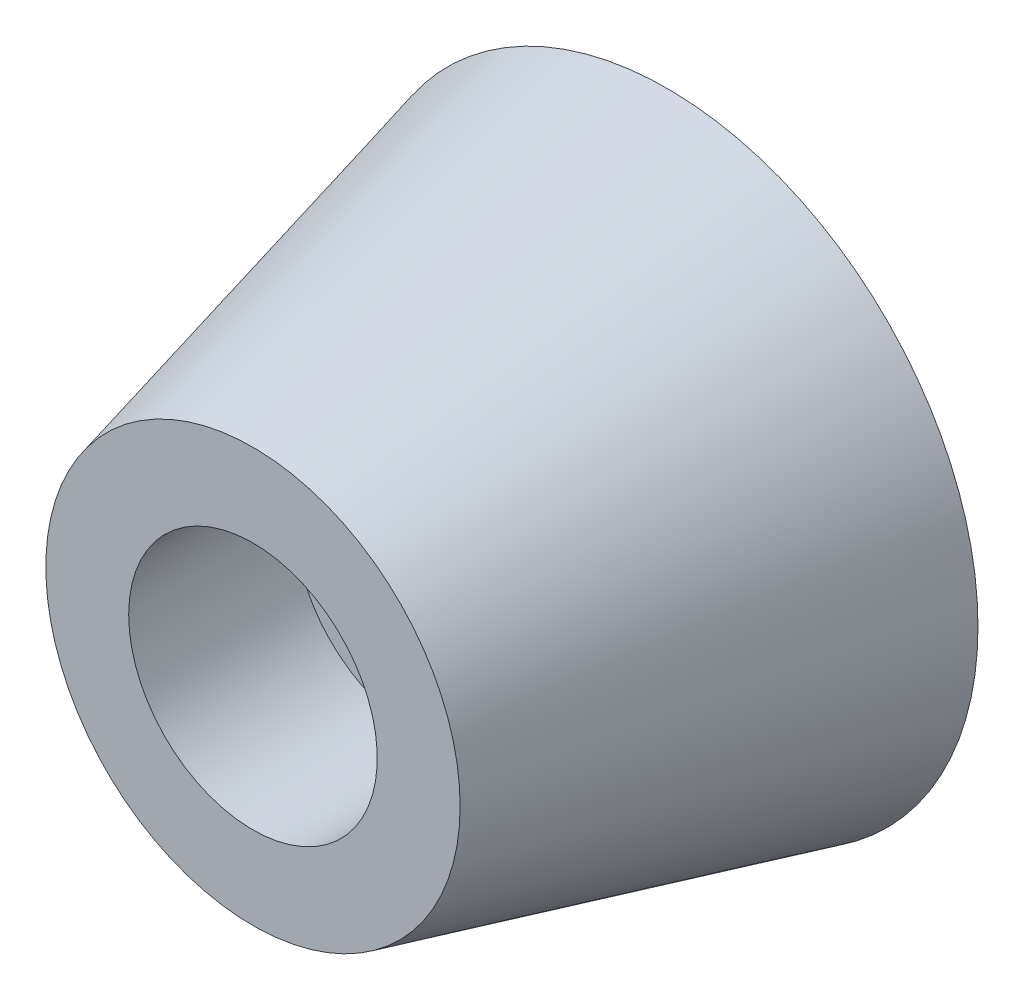
from build123d import *

# Parameters (mm, degrees)
SKETCH1_R          = 7.498550769
SKETCH2_R          = 5
SKETCH3_R          = 3
CUT_EXTRUDE1_DEPTH = 4
SKETCH4_R          = 1.75
CUT_EXTRUDE2_DEPTH = 10


with BuildPart() as part:
    # Sketch1 → Loft1 section 0
    with BuildSketch(Plane.XY):
        Circle(SKETCH1_R)
    # Sketch2 → Loft1 section 1
    with BuildSketch(Plane.XY.offset(10)):
        Circle(SKETCH2_R)
    loft()

    # Sketch3 → Cut-Extrude1 (cut)
    with BuildSketch(Plane(origin=(0, 0, 10), x_dir=(-1, 0, 0), z_dir=(0, 0, -1))):
        Circle(SKETCH3_R)
    extrude(amount=CUT_EXTRUDE1_DEPTH, mode=Mode.SUBTRACT)

    # Sketch4 → Cut-Extrude2 (cut)
    with BuildSketch(Plane.XY.offset(6)):
        Circle(SKETCH4_R)
    extrude(amount=-CUT_EXTRUDE2_DEPTH, mode=Mode.SUBTRACT)


solid = part.part
